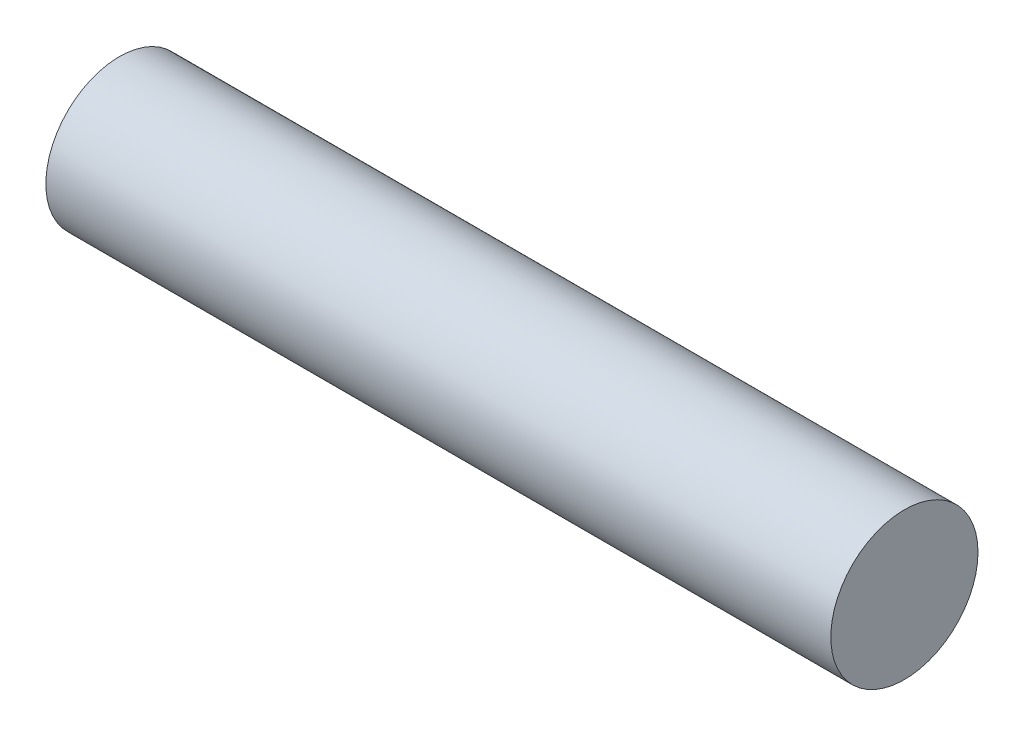
from build123d import *

# Parameters (mm, degrees)
SKETCH1_R           = 1.5
BOSS_EXTRUDE1_DEPTH = 16


with BuildPart() as part:
    # Sketch1 → Boss-Extrude1 (new body)
    with BuildSketch(Plane(origin=(0, 0, 0), x_dir=(0, 0, -1), z_dir=(1, 0, 0))):
        Circle(SKETCH1_R)
    extrude(amount=BOSS_EXTRUDE1_DEPTH)


solid = part.part
